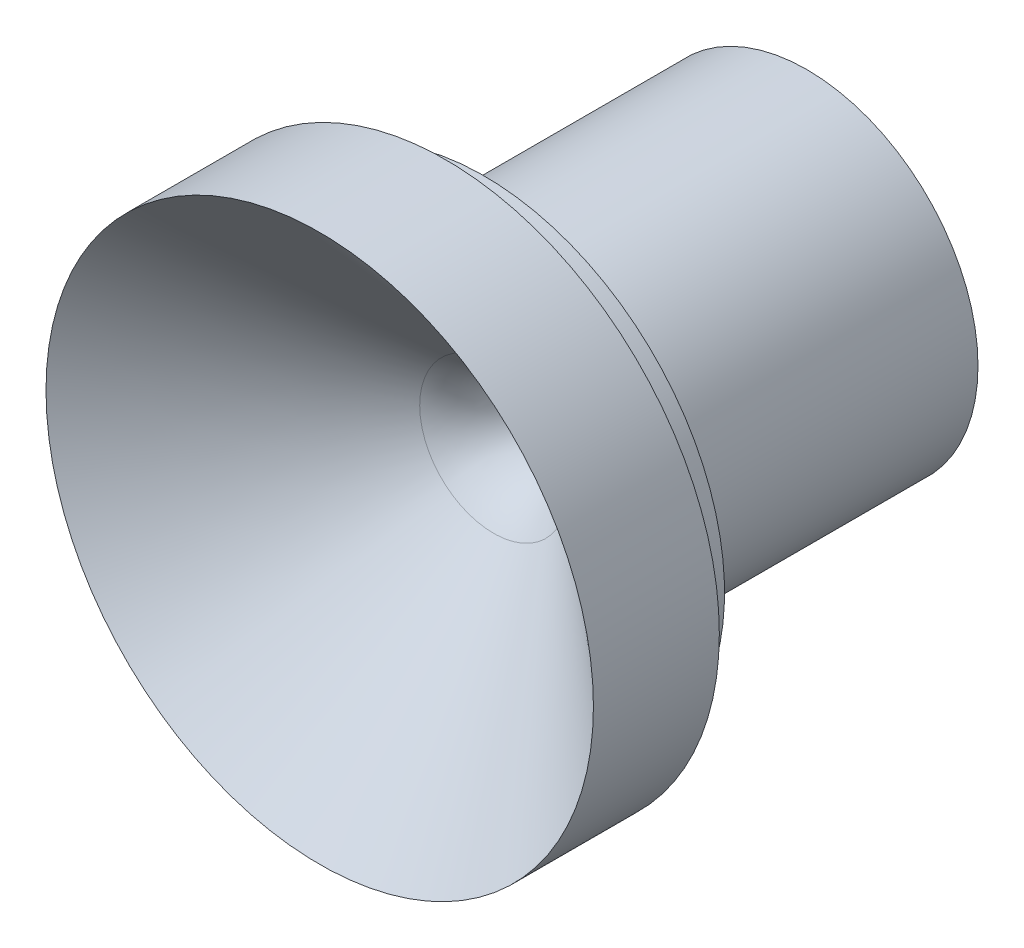
from build123d import *


with BuildPart() as part:
    # Sketch2 → Revolve1 (revolve)
    with BuildSketch(Plane(origin=(0, 0, 0), x_dir=(0, 0, -1), z_dir=(1, 0, 0))):
        with BuildLine():
            Line((10.946291784, 7.9375), (-2.210908216, 7.9375))
            Line((-2.210908216, 7.9375), (-4.039708216, 8.62311403))
            Line((-4.039708216, 8.62311403), (-4.039708216, 11.1633))
            Line((-4.039708216, 11.1633), (-5.817708216, 11.1633))
            Line((-5.817708216, 11.1633), (-5.817708216, 12.7))
            Line((-5.817708216, 12.7), (-11.659708216, 12.7))
            Line((-11.659708216, 12.7), (-3.593152451, 3.42739423))
            ThreePointArc((-3.593152451, 3.42739423), (-1.974177838, 2.219145534), (0, 1.7907))
            Line((0, 1.7907), (2.794, 1.7907))
            Line((2.794, 1.7907), (10.946291784, 3.9751))
            Line((10.946291784, 3.9751), (10.946291784, 7.9375))
        make_face()
    revolve(axis=Axis((0, 0, 0), (0, 0, 1)))


solid = part.part
